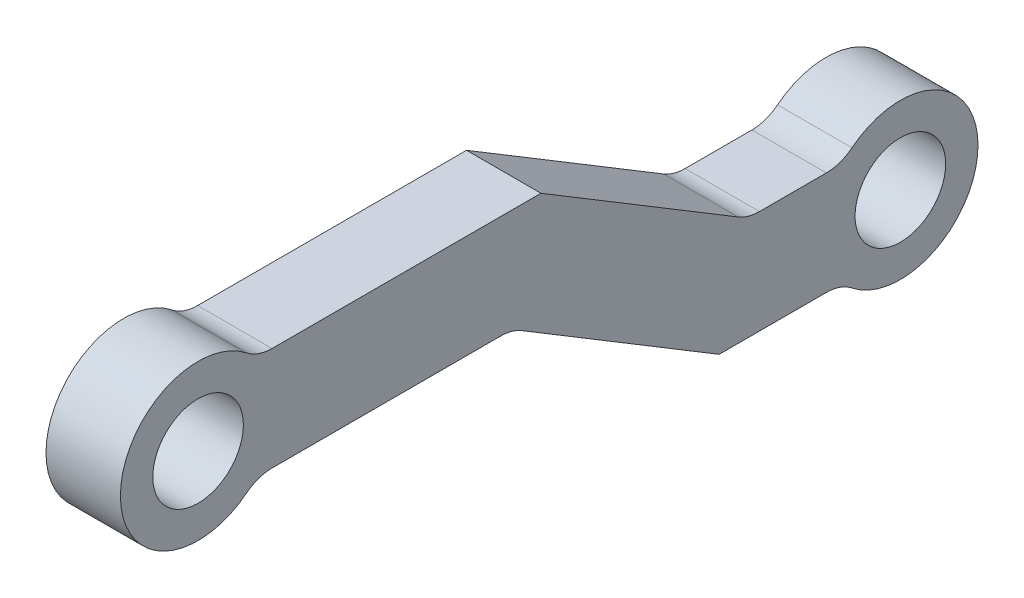
from build123d import *

# Parameters (mm, degrees)
SKETCH2_R           = 1.75
BOSS_EXTRUDE1_DEPTH = 2.875
FILLET1_R           = 1.5875


with BuildPart() as part:
    # Sketch2 → Boss-Extrude1 (new body)
    with BuildSketch(Plane(origin=(0, 0, 0), x_dir=(0, 0, -1), z_dir=(1, 0, 0))):
        with BuildLine():
            Line((13.247387042, 2), (2.236067977, 2))
            ThreePointArc((2.236067977, 2), (-3, 0), (2.236067977, -2))
            Line((2.236067977, -2), (12.13290764, -2))
            Line((12.13290764, -2), (20.13290764, -6.833106971))
            Line((20.13290764, -6.833106971), (24.896839663, -6.833106971))
            ThreePointArc((24.896839663, -6.833106971), (30.13290764, -4.833106971), (24.896839663, -2.833106971))
            Line((24.896839663, -2.833106971), (21.247387042, -2.833106971))
            Line((21.247387042, -2.833106971), (13.247387042, 2))
        make_face()
        Circle(SKETCH2_R, mode=Mode.SUBTRACT)
        with Locations((27.13290764, -4.833106971)):
            Circle(SKETCH2_R, mode=Mode.SUBTRACT)
    extrude(amount=BOSS_EXTRUDE1_DEPTH)

    # Fillet1
    fillet1_edges = [part.edges().sort_by_distance(p)[0] for p in [
        (1.4375, -6.833106971, -24.896839663),
        (1.4375, -2, -12.13290764),
        (1.4375, -2, -2.236067977),
        (1.4375, 2, -2.236067977),
        (1.4375, -2.833106971, -21.247387042),
        (1.4375, -2.833106971, -24.896839663),
    ]]
    fillet(fillet1_edges, radius=FILLET1_R)


solid = part.part
